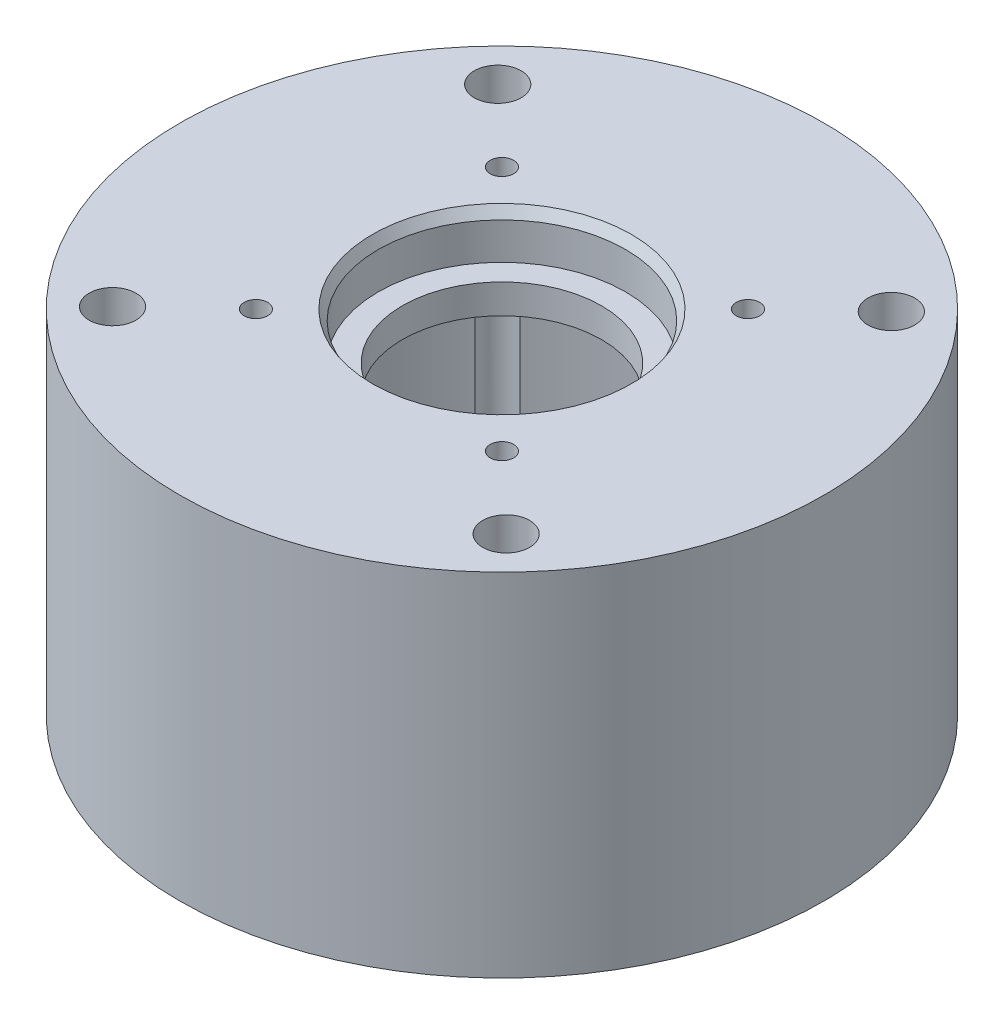
from build123d import *

# Parameters (mm, degrees)
SKETCH_1_R          = 55
EXTRUDE_1_DEPTH     = 60
SKETCH_2_R          = 50
CUT_EXTRUDE_1_DEPTH = 47
SKETCH_3_R          = 17
CUT_EXTRUDE_2_DEPTH = 14
SKETCH_4_R          = 4
CUT_EXTRUDE_3_DEPTH = 61
SKETCH1_R           = 21.1
CUT_EXTRUDE1_DEPTH  = 8
CHAMFER1_SIZE       = 1
CHAMFER1_SIZE2      = 1.732050808
SKETCH2_R           = 2
CUT_EXTRUDE2_DEPTH  = 61
CUT_EXTRUDE3_DEPTH  = 4


with BuildPart() as part:
    # Эскиз1 → Бобышка-Вытянуть1 (new body)
    with BuildSketch(Plane(origin=(0, 0, 0), x_dir=(1, 0, 0), z_dir=(0, 1, 0))):
        with Locations(Location((0, 0, 0), (0, 0, 270))):  # turned: the seam where the file's is
            Circle(SKETCH_1_R)
    extrude(amount=EXTRUDE_1_DEPTH)

    # Эскиз2 → Вырез-Вытянуть1 (cut)
    with BuildSketch(Plane.XZ):
        with Locations(Location((0, 0, 0), (0, 0, 270))):  # turned: the seam where the file's is
            Circle(SKETCH_2_R)
    extrude(amount=-CUT_EXTRUDE_1_DEPTH, mode=Mode.SUBTRACT)

    # Эскиз3 → Вырез-Вытянуть2 (cut, through all)
    with BuildSketch(Plane.XZ.offset(-47)):
        with Locations(Location((0, 0, 0), (0, 0, 270))):  # turned: the seam where the file's is
            Circle(SKETCH_3_R)
    extrude(amount=-CUT_EXTRUDE_2_DEPTH, mode=Mode.SUBTRACT)

    # Эскиз4 → Вырез-Вытянуть3 (cut, through all)
    with BuildSketch(Plane(origin=(0, 60, 0), x_dir=(1, 0, 0), z_dir=(0, 1, 0))):
        with Locations(Location((33.591727056, -32.872418125, 0), (0, 0, 270))):  # turned: the seam where the file's is
            Circle(SKETCH_4_R)
        with Locations(Location((-33.591727056, -32.872418125, 0), (0, 0, 270))):  # turned: the seam where the file's is
            Circle(SKETCH_4_R)
        with Locations(Location((-33.591727056, 32.872418125, 0), (0, 0, 270))):  # turned: the seam where the file's is
            Circle(SKETCH_4_R)
        with Locations(Location((33.591727056, 32.872418125, 0), (0, 0, 270))):  # turned: the seam where the file's is
            Circle(SKETCH_4_R)
    extrude(amount=-CUT_EXTRUDE_3_DEPTH, mode=Mode.SUBTRACT)

    # Sketch1 → Cut-Extrude1 (cut)
    with BuildSketch(Plane(origin=(0, 60, 0), x_dir=(1, 0, 0), z_dir=(0, 1, 0))):
        with Locations(Location((0, 0, 0), (0, 0, 270))):  # turned: the seam where the file's is
            Circle(SKETCH1_R)
    extrude(amount=-CUT_EXTRUDE1_DEPTH, mode=Mode.SUBTRACT)

    # Chamfer1
    chamfer1_edges = [part.edges().sort_by_distance(p)[0] for p in [
        (0, 60, -21.1),
    ]]
    chamfer1_side = [part.faces().sort_by_distance(p)[0] for p in [
        (0, 60, -53.444365081),
    ]]
    chamfer(chamfer1_edges, length=CHAMFER1_SIZE, length2=CHAMFER1_SIZE2, reference=chamfer1_side[0])

    # Sketch2 → Cut-Extrude2 (cut, through all)
    with BuildSketch(Plane(origin=(0, 60, 0), x_dir=(1, 0, 0), z_dir=(0, 1, 0))):
        with Locations(Location((21, 21, 0), (0, 0, 270))):  # turned: the seam where the file's is
            Circle(SKETCH2_R)
        with Locations(Location((-21, 21, 0), (0, 0, 270))):  # turned: the seam where the file's is
            Circle(SKETCH2_R)
        with Locations(Location((21, -21, 0), (0, 0, 270))):  # turned: the seam where the file's is
            Circle(SKETCH2_R)
        with Locations(Location((-21, -21, 0), (0, 0, 270))):  # turned: the seam where the file's is
            Circle(SKETCH2_R)
    extrude(amount=-CUT_EXTRUDE2_DEPTH, mode=Mode.SUBTRACT)

    # Sketch3 → Cut-Extrude3 (cut)
    with BuildSketch(Plane.XZ.offset(-47)):
        Polygon((-21, -16.9), (-24.550704156, -18.95), (-24.550704156, -23.05), (-21, -25.1), (-17.449295844, -23.05), (-17.449295844, -18.95), align=None)
        Polygon((-21, 25.1), (-24.550704156, 23.05), (-24.550704156, 18.95), (-21, 16.9), (-17.449295844, 18.95), (-17.449295844, 23.05), align=None)
        Polygon((24.550704156, 23.05), (21, 25.1), (17.449295844, 23.05), (17.449295844, 18.95), (21, 16.9), (24.550704156, 18.95), align=None)
        Polygon((24.550704156, -18.95), (21, -16.9), (17.449295844, -18.95), (17.449295844, -23.05), (21, -25.1), (24.550704156, -23.05), align=None)
    extrude(amount=-CUT_EXTRUDE3_DEPTH, mode=Mode.SUBTRACT)


solid = part.part
